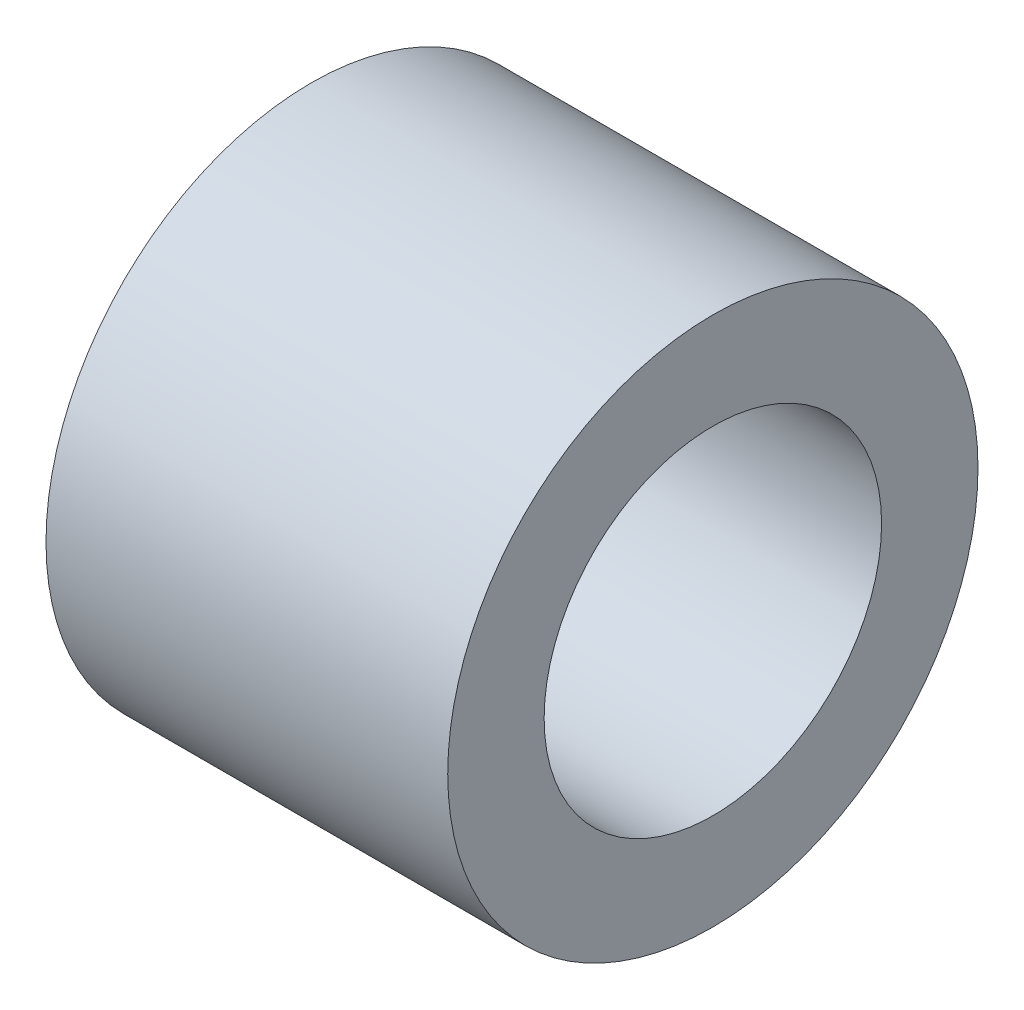
from build123d import *

# Parameters (mm, degrees)
SKETCH1_R           = 3.3
SKETCH1_R_2         = 2.1
BOSS_EXTRUDE1_DEPTH = 5


with BuildPart() as part:
    # Sketch1 → Boss-Extrude1 (new body)
    with BuildSketch(Plane(origin=(0, 0, 0), x_dir=(0, 0, -1), z_dir=(1, 0, 0))):
        Circle(SKETCH1_R)
        Circle(SKETCH1_R_2, mode=Mode.SUBTRACT)
    extrude(amount=BOSS_EXTRUDE1_DEPTH)


solid = part.part
